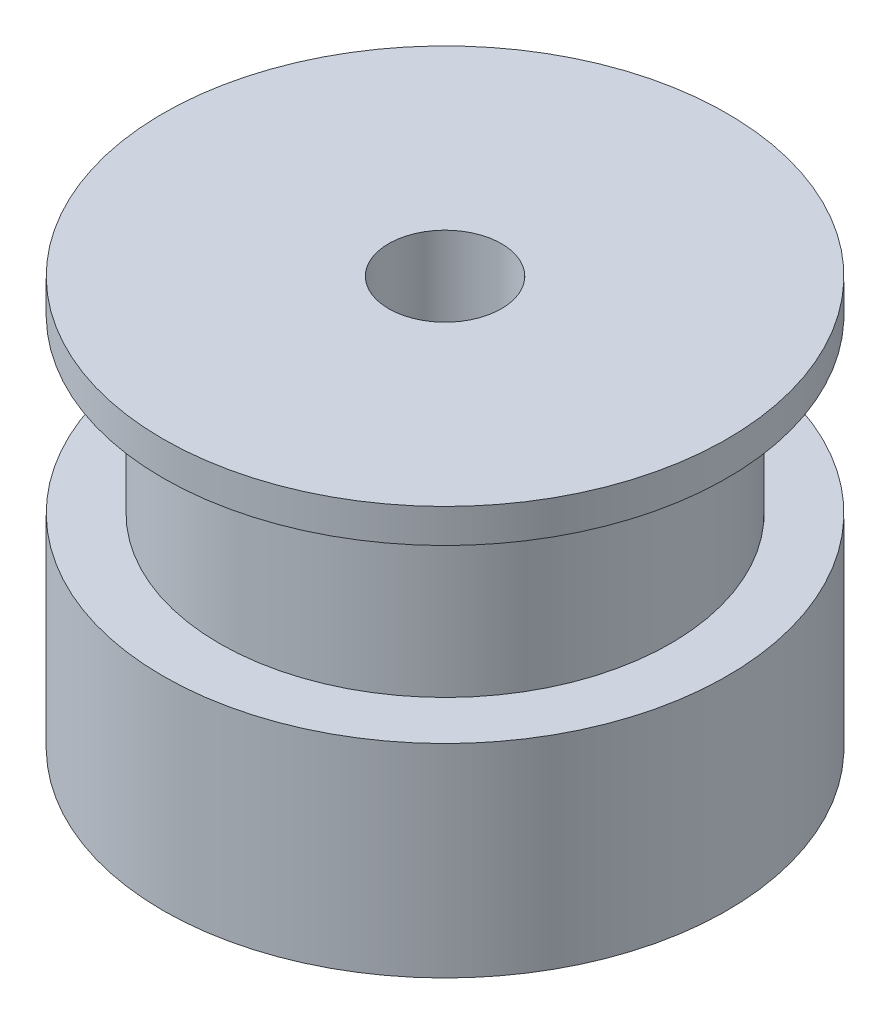
from build123d import *

# Parameters (mm, degrees)
SKETCH1_R           = 12.5
BOSS_EXTRUDE1_DEPTH = 9
SKETCH2_R           = 10
BOSS_EXTRUDE2_DEPTH = 7.6
SKETCH3_R           = 12.5
BOSS_EXTRUDE3_DEPTH = 1.5
SKETCH4_R           = 2.5
CUT_EXTRUDE1_DEPTH  = 19.1


with BuildPart() as part:
    # Sketch1 → Boss-Extrude1 (new body)
    with BuildSketch(Plane(origin=(0, 0, 0), x_dir=(1, 0, 0), z_dir=(0, 1, 0))):
        Circle(SKETCH1_R)
    extrude(amount=BOSS_EXTRUDE1_DEPTH)

    # Sketch2 → Boss-Extrude2 (add)
    with BuildSketch(Plane(origin=(0, 9, 0), x_dir=(1, 0, 0), z_dir=(0, 1, 0))):
        Circle(SKETCH2_R)
    extrude(amount=BOSS_EXTRUDE2_DEPTH)

    # Sketch3 → Boss-Extrude3 (add)
    with BuildSketch(Plane(origin=(0, 16.6, 0), x_dir=(1, 0, 0), z_dir=(0, 1, 0))):
        Circle(SKETCH3_R)
    extrude(amount=BOSS_EXTRUDE3_DEPTH)

    # Sketch4 → Cut-Extrude1 (cut, through all)
    with BuildSketch(Plane(origin=(0, 18.1, 0), x_dir=(1, 0, 0), z_dir=(0, 1, 0))):
        Circle(SKETCH4_R)
    extrude(amount=-CUT_EXTRUDE1_DEPTH, mode=Mode.SUBTRACT)


solid = part.part
